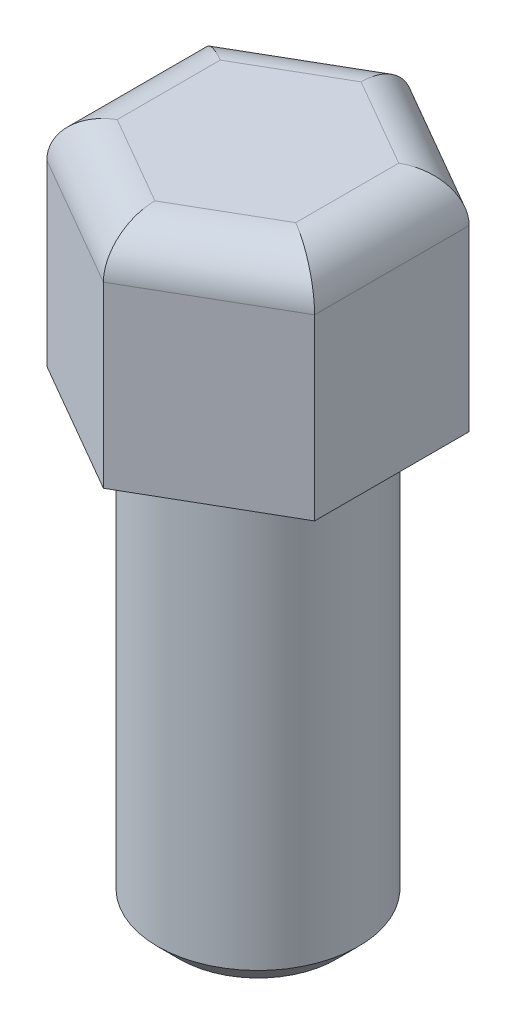
from build123d import *

# Parameters (mm, degrees)
SKETCH_1_R      = 4.5
EXTRUDE_1_DEPTH = 20
EXTRUDE_2_DEPTH = 10
CHAMFER_2_SIZE  = 1
FILLET_1_R      = 2


with BuildPart() as part:
    # 草圖1 → 填料-伸長1 (new body)
    with BuildSketch(Plane(origin=(0, 0, 0), x_dir=(1, 0, 0), z_dir=(0, 1, 0))):
        Circle(SKETCH_1_R)
    extrude(amount=EXTRUDE_1_DEPTH)

    # 草圖2 → 填料-伸長2 (add)
    with BuildSketch(Plane(origin=(0, 20, 0), x_dir=(1, 0, 0), z_dir=(0, 1, 0))):
        Polygon((6, 3.464101615), (0, 6.92820323), (-6, 3.464101615), (-6, -3.464101615), (0, -6.92820323), (6, -3.464101615), align=None)
    extrude(amount=EXTRUDE_2_DEPTH)

    # 導角2
    chamfer_2_edges = [part.edges().sort_by_distance(p)[0] for p in [
        (-4.5, 0, 0),
        (-4.5, 20, 0),
    ]]
    chamfer(chamfer_2_edges, length=CHAMFER_2_SIZE)

    # 圓角1
    fillet_1_edges = [part.edges().sort_by_distance(p)[0] for p in [
        (6, 30, 0),
        (3, 30, -5.196152423),
        (-3, 30, -5.196152423),
        (-6, 30, 0),
        (-3, 30, 5.196152423),
        (3, 30, 5.196152423),
    ]]
    fillet(fillet_1_edges, radius=FILLET_1_R)


solid = part.part
